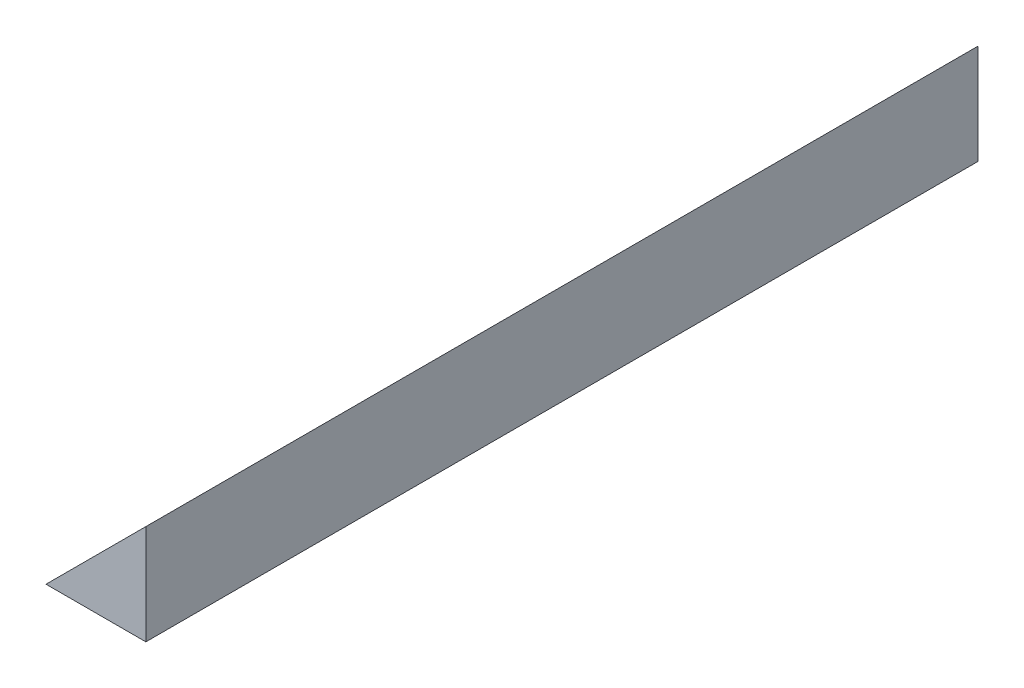
from build123d import *

# Parameters (mm, degrees)
EXTRUDE_1_DEPTH = 50


with BuildPart() as part:
    # Эскиз1 → Вытянуть1 (new body)
    with BuildSketch(Plane.XY):
        Polygon((-6, 0), (0, 0), (0, 6), align=None)
    extrude(amount=EXTRUDE_1_DEPTH)


solid = part.part
